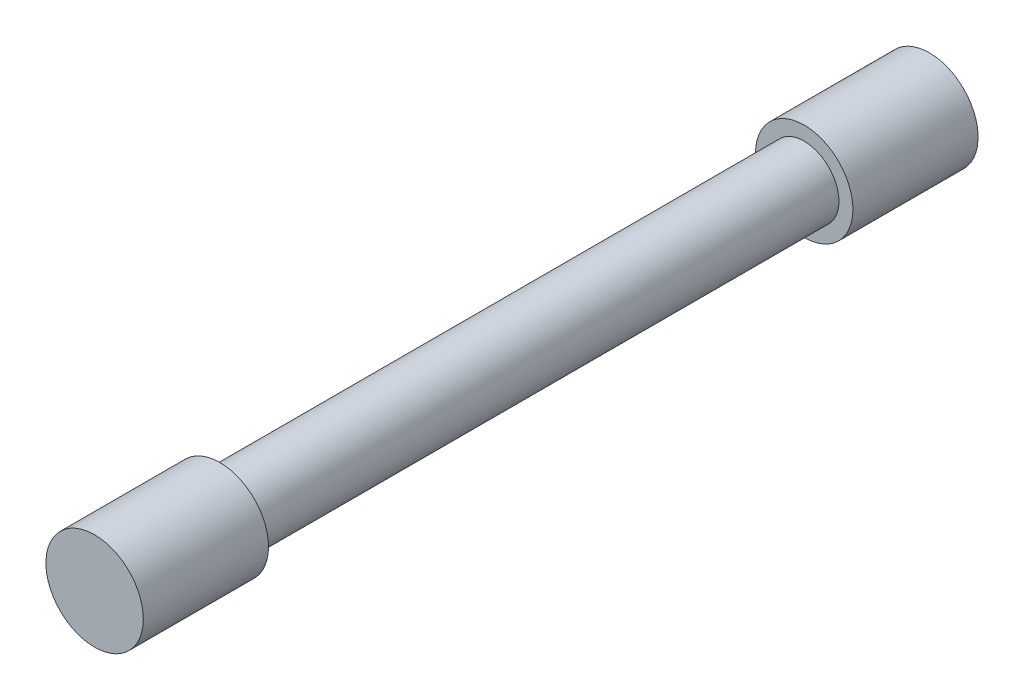
from build123d import *

# Parameters (mm, degrees)
SKETCH_1_R      = 7
EXTRUDE_1_DEPTH = 18
SKETCH_2_R      = 5
EXTRUDE_2_DEPTH = 84
SKETCH_3_R      = 7
EXTRUDE_3_DEPTH = 18


with BuildPart() as part:
    # 草图1 → 凸台-拉伸1 (new body)
    with BuildSketch(Plane.XY):
        Circle(SKETCH_1_R)
    extrude(amount=EXTRUDE_1_DEPTH)

    # 草图2 → 凸台-拉伸2 (add)
    with BuildSketch(Plane(origin=(0, 0, 0), x_dir=(-1, 0, 0), z_dir=(0, 0, -1))):
        Circle(SKETCH_2_R)
    extrude(amount=EXTRUDE_2_DEPTH)

    # 草图3 → 凸台-拉伸3 (add)
    with BuildSketch(Plane(origin=(0, 0, -84), x_dir=(-1, 0, 0), z_dir=(0, 0, -1))):
        Circle(SKETCH_3_R)
    extrude(amount=EXTRUDE_3_DEPTH)


solid = part.part
